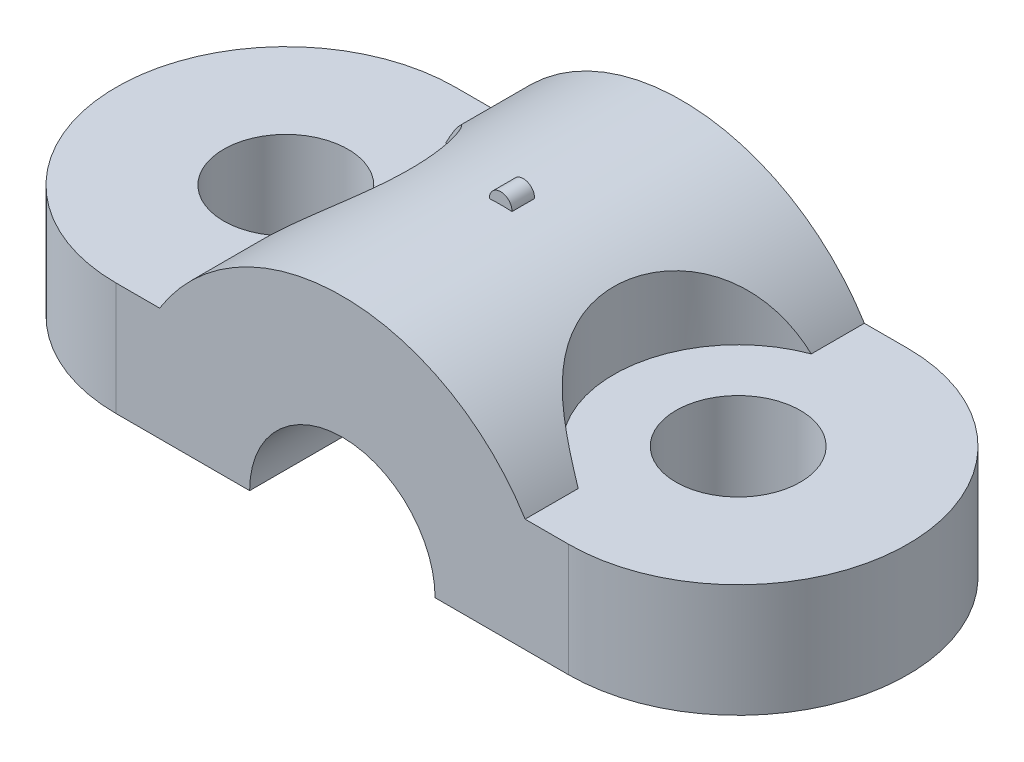
from build123d import *

# Parameters (mm, degrees)
BOSS_EXTRUDE1_DEPTH = 9.5
SKETCH1_3_R         = 2.75
BOSS_EXTRUDE2_DEPTH = 5
CUT_EXTRUDE2_DEPTH  = 25.929901725
BOSS_EXTRUDE3_DEPTH = 0.5


with BuildPart() as part:
    # Sketch1 → Boss-Extrude1 (new body)
    with BuildSketch(Plane(origin=(0, 0, 0), x_dir=(1, 0, 0), z_dir=(0, 1, 0))):
        with BuildLine():
            Line((8.08, 7.5), (-8.08, 7.5))
            Line((-8.08, 7.5), (-8.08, 5.153988747))
            ThreePointArc((-8.08, 5.153988747), (-4.5, 0), (-8.08, -5.153988747))
            Line((-8.08, -5.153988747), (-8.08, -7.5))
            Line((-8.08, -7.5), (8.08, -7.5))
            Line((8.08, -7.5), (8.08, -5.153988747))
            ThreePointArc((8.08, -5.153988747), (4.5, 0), (8.08, 5.153988747))
            Line((8.08, 5.153988747), (8.08, 7.5))
        make_face()
    extrude(amount=BOSS_EXTRUDE1_DEPTH)

    # Sketch1_3 → Boss-Extrude2 (add)
    # profile 1 of 2: a face of its own
    with BuildSketch(Plane(origin=(0, 0, 0), x_dir=(1, 0, 0), z_dir=(0, 1, 0))):
        with BuildLine():
            Line((-8.08, 5.153988747), (-8.08, 7.5))
            Line((-8.08, 7.5), (-10, 7.5))
            ThreePointArc((-10, 7.5), (-17.5, 0), (-10, -7.5))
            Line((-10, -7.5), (-8.08, -7.5))
            Line((-8.08, -7.5), (-8.08, -5.153988747))
            ThreePointArc((-8.08, -5.153988747), (-4.5, 0), (-8.08, 5.153988747))
        make_face()
        with Locations((-10, 0)):
            Circle(SKETCH1_3_R, mode=Mode.SUBTRACT)
    # profile 2 of 2: a face of its own
    with BuildSketch(Plane(origin=(0, 0, 0), x_dir=(1, 0, 0), z_dir=(0, 1, 0))):
        with BuildLine():
            Line((10, 7.5), (8.08, 7.5))
            Line((8.08, 7.5), (8.08, 5.153988747))
            ThreePointArc((8.08, 5.153988747), (4.5, 0), (8.08, -5.153988747))
            Line((8.08, -5.153988747), (8.08, -7.5))
            Line((8.08, -7.5), (10, -7.5))
            ThreePointArc((10, -7.5), (17.5, 0), (10, 7.5))
        make_face()
        with Locations((10, 0)):
            Circle(SKETCH1_3_R, mode=Mode.SUBTRACT)
    extrude(amount=BOSS_EXTRUDE2_DEPTH)

    # Sketch3 → Cut-Extrude2 (cut, through all)
    with BuildSketch(Plane.XY.offset(7.5)):
        with BuildLine():
            Line((1.6e-08, 9.5), (-8.08, 9.5))
            Line((-8.08, 9.5), (-8.08, 5))
            ThreePointArc((-8.08, 5), (-4.624294534, 8.299133313), (1.6e-08, 9.5))
        make_face()
        with BuildLine():
            Line((8.08, 9.5), (1.6e-08, 9.5))
            ThreePointArc((1.6e-08, 9.5), (4.624294548, 8.299133305), (8.08, 5))
            Line((8.08, 5), (8.08, 9.5))
        make_face()
        with BuildLine():
            Line((-4.1, 0), (4.1, 0))
            ThreePointArc((4.1, 0), (0, 4.1), (-4.1, 0))
        make_face()
    extrude(amount=-CUT_EXTRUDE2_DEPTH, mode=Mode.SUBTRACT)

    # Sketch7 → Boss-Extrude3 (add, symmetric)
    with BuildSketch(Plane.XY):
        with BuildLine():
            ThreePointArc((-0.499826987, 9.486847705), (0, 9.5), (0.499826987, 9.486847705))
            ThreePointArc((0.499826987, 9.486847705), (0, 10), (-0.499826987, 9.486847705))
        make_face()
    extrude(amount=BOSS_EXTRUDE3_DEPTH, both=True)


solid = part.part
